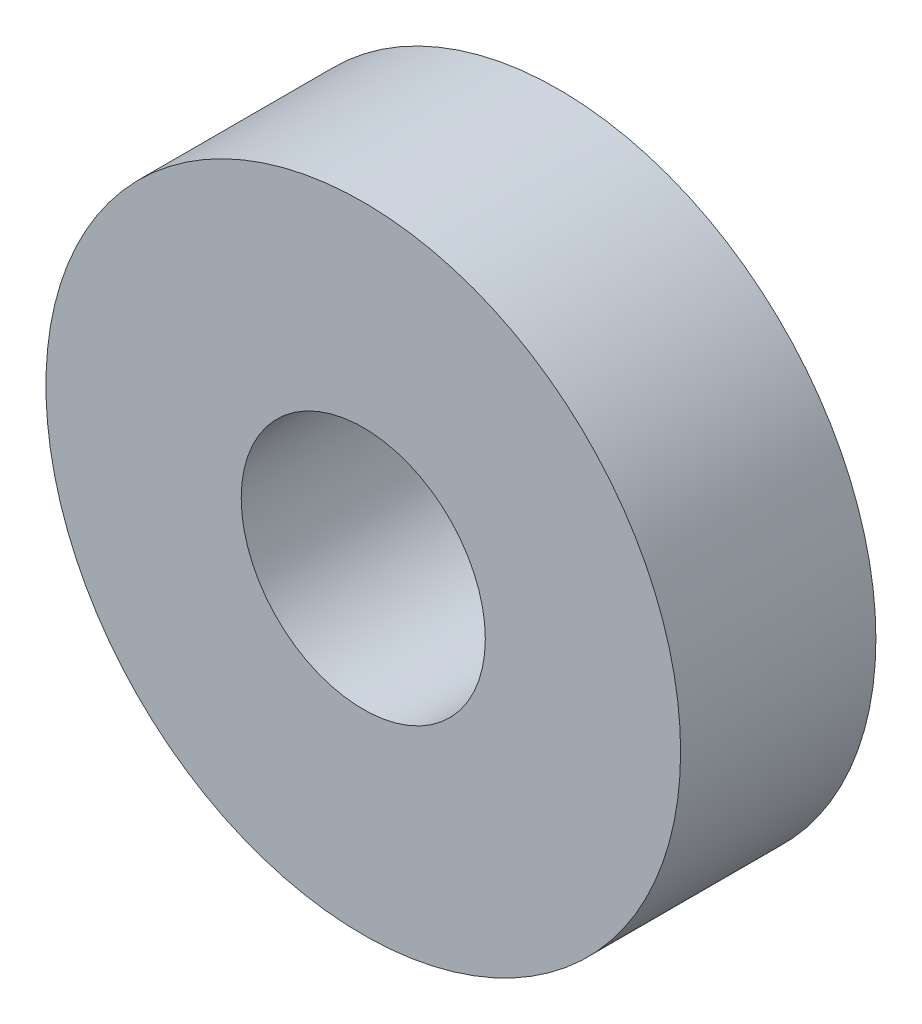
from build123d import *

# Parameters (mm, degrees)
CROQUIS1_R              = 13
CROQUIS1_R_2            = 5
SALIENTE_EXTRUIR1_DEPTH = 8


with BuildPart() as part:
    # Croquis1 → Saliente-Extruir1 (new body)
    with BuildSketch(Plane.XY):
        Circle(CROQUIS1_R)
        Circle(CROQUIS1_R_2, mode=Mode.SUBTRACT)
    extrude(amount=SALIENTE_EXTRUIR1_DEPTH)


solid = part.part
